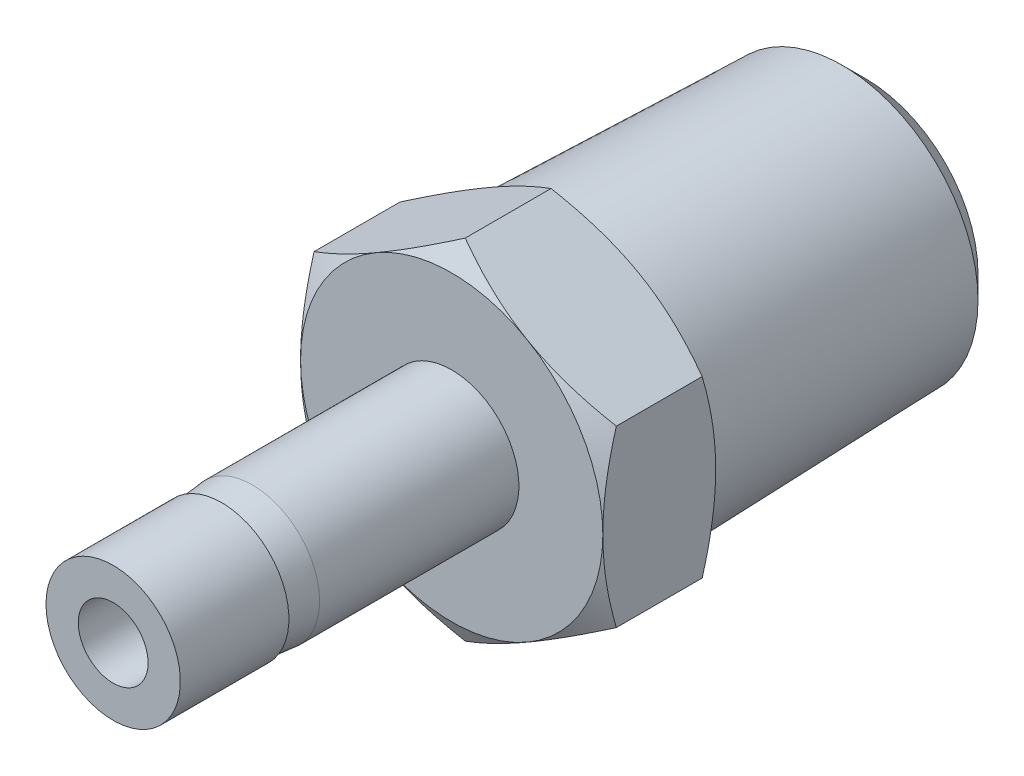
from build123d import *

# Parameters (mm, degrees)
BOSS_EXTRUDE1_DEPTH = 5.334
SKETCH4_W           = 21.336
SKETCH4_H           = 1.651


with BuildPart() as part:
    # Sketch2 → Revolve1 (revolve)
    with BuildSketch(Plane(origin=(0, 0, 0), x_dir=(0, 0, -1), z_dir=(1, 0, 0))):
        Polygon((5.1308, 3.175), (5.1308, 3.048), (6.582416642, 3.175), (16.002, 3.175), (16.002, 0), (0, 0), (0, 3.175), align=None)
    revolve(axis=Axis((0, 0, -16.002), (0, 0, 1)))

    # Sketch3 → Boss-Extrude1 (add)
    with BuildSketch(Plane(origin=(0, 0, -16.002), x_dir=(-1, 0, 0), z_dir=(0, 0, -1))):
        Polygon((0, 8.248891971), (-7.14375, 4.124445986), (-7.14375, -4.124445986), (0, -8.248891971), (7.14375, -4.124445986), (7.14375, 4.124445986), align=None)
    extrude(amount=BOSS_EXTRUDE1_DEPTH)

    # Sketch4 → Cut-Revolve1 (revolve, cut)
    with BuildSketch(Plane(origin=(0, 0, 0), x_dir=(0, 0, -1), z_dir=(1, 0, 0))):
        Polygon((16.002, 8.248891971), (16.002, 7.14375), (16.640054014, 8.248891971), (20.697945986, 8.248891971), (21.336, 7.14375), (21.336, 8.248891971), (21.336, 9.354033942), (16.002, 9.354033942), align=None)
        with Locations((10.668, 0.8255)):
            Rectangle(SKETCH4_W, SKETCH4_H)
    revolve(axis=Axis((0, 0, 0), (0, 0, -1)), mode=Mode.SUBTRACT)


with BuildPart() as body_2:
    # Sketch5 → Revolve2 (revolve)
    with BuildSketch(Plane(origin=(0, 0, 0), x_dir=(0, 0, -1), z_dir=(1, 0, 0))):
        Polygon((20.45716, 0), (35.56, 0), (35.56, 6.38777167), (20.45716, 6.858), align=None)
    revolve(axis=Axis((0, 0, -20.45716), (0, 0, -1)))


with BuildPart() as part_1:
    add(part.part)

    # Combine1: union body 2
    add(body_2.part)

    # Sketch8 → Cut-Revolve2 (revolve, cut)
    with BuildSketch(Plane(origin=(0, 0, 0), x_dir=(0, 0, -1), z_dir=(1, 0, 0))):
        Polygon((35.56, 5.318470859), (34.33794193, 6.540528929), (35.56, 6.540528929), align=None)
        Polygon((35.56, 4.6228), (20.45716, 4.6228), (17.67950153, 0), (35.56, 0), align=None)
    revolve(axis=Axis((0, 0, 0), (0, 0, -1)), mode=Mode.SUBTRACT)


solid = part_1.part
